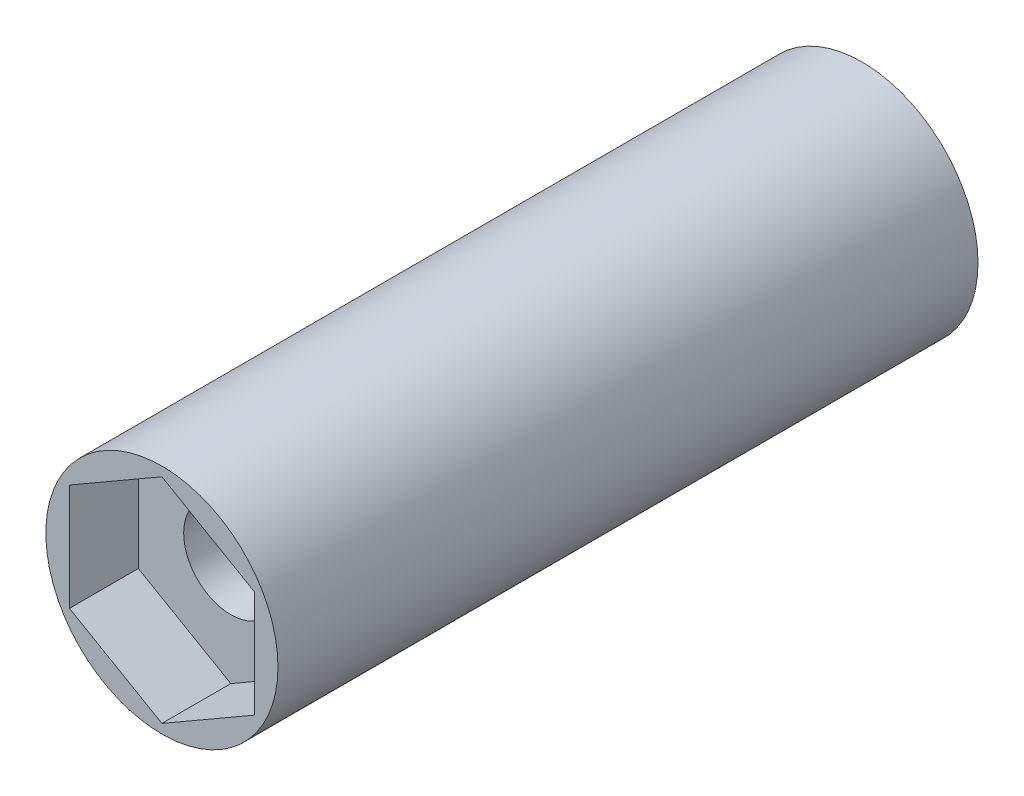
from build123d import *

# Parameters (mm, degrees)
SKETCH1_R           = 3.2
SKETCH1_R_2         = 2.929016319
BOSS_EXTRUDE1_DEPTH = 2.2
SKETCH2_R           = 3.2
SKETCH2_R_2         = 1.3
BOSS_EXTRUDE2_DEPTH = 15.2
SKETCH3_R           = 3.2
BOSS_EXTRUDE3_DEPTH = 1.9
SKETCH4_R           = 1.3
BOSS_EXTRUDE4_DEPTH = 0.2


with BuildPart() as part:
    # Sketch1 → Boss-Extrude1 (new body)
    with BuildSketch(Plane.XY):
        with Locations((-32.2, 44.45)):
            Circle(SKETCH1_R)
        with Locations((-32.2, 44.45)):
            Circle(SKETCH1_R_2, mode=Mode.SUBTRACT)
    extrude(amount=BOSS_EXTRUDE1_DEPTH)

    # Sketch2 → Boss-Extrude2 (add)
    with BuildSketch(Plane.XY.offset(2.2)):
        with Locations((-32.2, 44.45)):
            Circle(SKETCH2_R)
        with Locations((-32.2, 44.45)):
            Circle(SKETCH2_R_2, mode=Mode.SUBTRACT)
    extrude(amount=BOSS_EXTRUDE2_DEPTH)

    # Sketch3 → Boss-Extrude3 (add)
    with BuildSketch(Plane.XY.offset(17.4)):
        with Locations((-32.2, 44.45)):
            Circle(SKETCH3_R)
        Polygon((-34.75, 42.977756814), (-32.2, 41.505513627), (-29.65, 42.977756814), (-29.65, 45.922243186), (-32.2, 47.394486373), (-34.75, 45.922243186), align=None, mode=Mode.SUBTRACT)
    extrude(amount=BOSS_EXTRUDE3_DEPTH)

    # Sketch4 → Boss-Extrude4 (add)
    with BuildSketch(Plane(origin=(0, 0, 2.2), x_dir=(-1, 0, 0), z_dir=(0, 0, -1))):
        with Locations((32.2, 44.45)):
            Circle(SKETCH4_R)
    extrude(amount=-BOSS_EXTRUDE4_DEPTH)


solid = part.part
